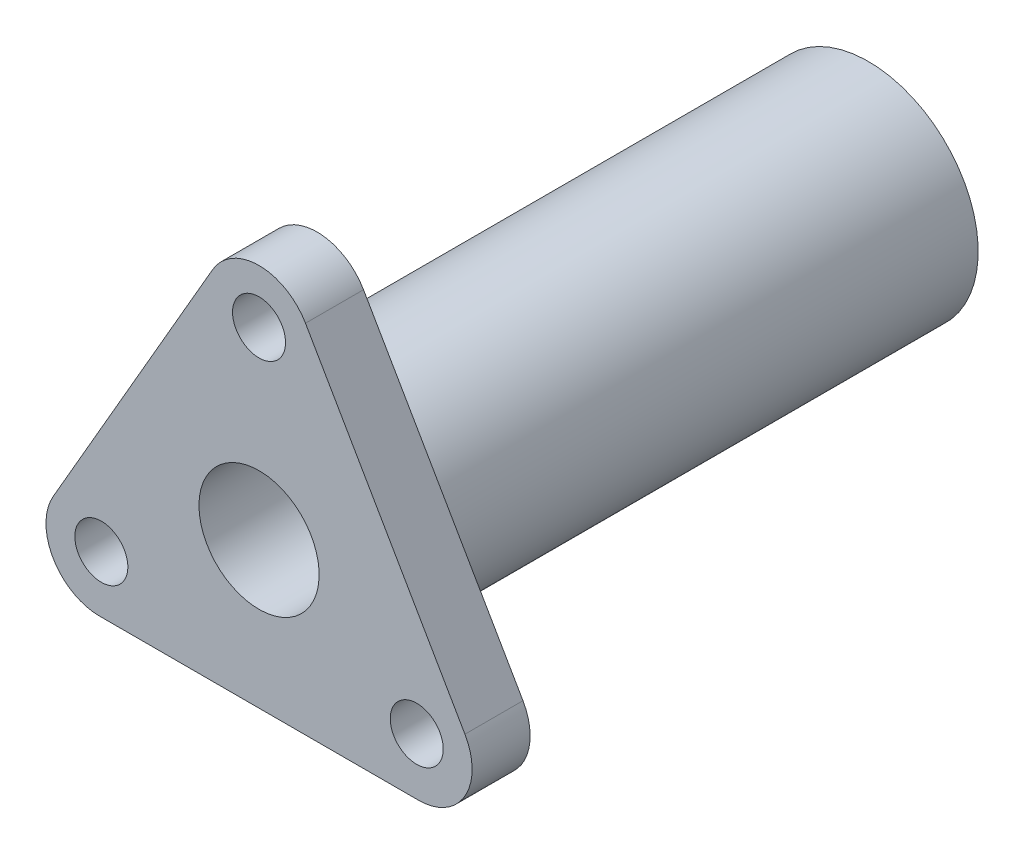
from build123d import *

# Parameters (mm, degrees)
BOSS_EXTRUDE1_DEPTH   = 4.6
M5X0_8_TAPPED_HOLE1_D = 4.2
FILLET1_R             = 4.25
SKETCH9_R             = 8.7
BOSS_EXTRUDE2_DEPTH   = 43.7
SKETCH10_R            = 4.7625
CUT_EXTRUDE1_DEPTH    = 48.3


with BuildPart() as part:
    # Sketch1 → Boss-Extrude1 (new body)
    with BuildSketch(Plane.XY):
        Polygon((0, 23.094010768), (20, -11.547005384), (-20, -11.547005384), align=None)
    extrude(amount=BOSS_EXTRUDE1_DEPTH)

    # M5x0.8 Tapped Hole1 (through all)
    with Locations(Plane(origin=(0, 0, 0), x_dir=(-1, 0, 0), z_dir=(0, 0, -1))):
        with Locations((0, 14.594010768), (-12.5, -7.056624327), (12.5, -7.056624327)):
            Hole(M5X0_8_TAPPED_HOLE1_D / 2)

    # Fillet1
    fillet1_edges = [part.edges().sort_by_distance(p)[0] for p in [
        (0, 23.094010768, 2.3),
        (20, -11.547005384, 2.3),
        (-20, -11.547005384, 2.3),
    ]]
    fillet(fillet1_edges, radius=FILLET1_R)

    # Sketch9 → Boss-Extrude2 (add)
    with BuildSketch(Plane(origin=(0, 0, 0), x_dir=(-1, 0, 0), z_dir=(0, 0, -1))):
        Circle(SKETCH9_R)
    extrude(amount=BOSS_EXTRUDE2_DEPTH)

    # Sketch10 → Cut-Extrude1 (cut)
    with BuildSketch(Plane(origin=(0, 0, -43.7), x_dir=(-1, 0, 0), z_dir=(0, 0, -1))):
        Circle(SKETCH10_R)
    extrude(amount=-CUT_EXTRUDE1_DEPTH, mode=Mode.SUBTRACT)


solid = part.part
